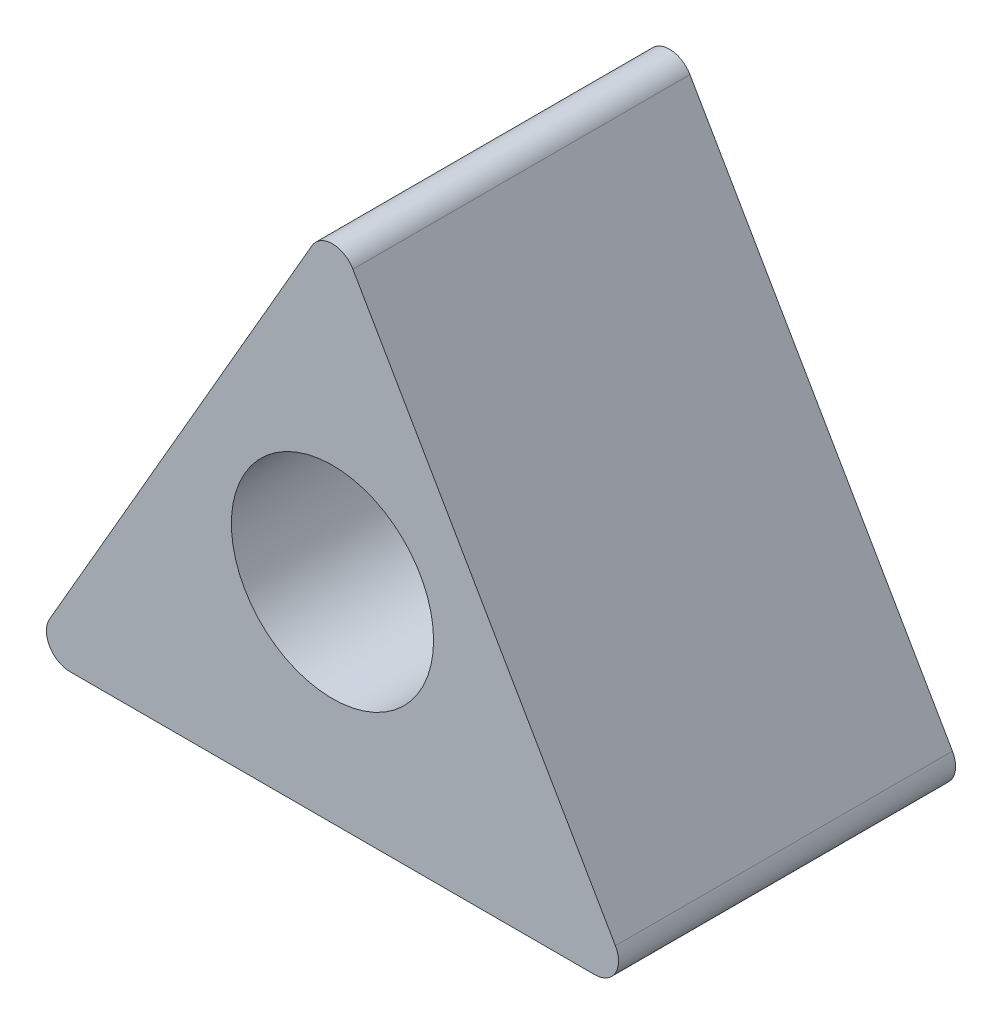
from build123d import *

# Parameters (mm, degrees)
SKETCH1_R           = 15
BOSS_EXTRUDE2_DEPTH = 50
FILLET1_R           = 3.5
FILLET2_R           = 3.5
FILLET3_R           = 3.5


with BuildPart() as part:
    # Sketch1 → Boss-Extrude2 (new body)
    with BuildSketch(Plane.XY):
        Polygon((0, 0), (89.999999993, 0.001126334), (44.999024562, 77.942849502), align=None)
        with Locations((45, 31)):
            Circle(SKETCH1_R, mode=Mode.SUBTRACT)
    extrude(amount=BOSS_EXTRUDE2_DEPTH)

    # Fillet1
    fillet1_edges = [part.edges().sort_by_distance(p)[0] for p in [
        (44.999024562, 77.942849502, 25),
    ]]
    fillet(fillet1_edges, radius=FILLET1_R)

    # Fillet2
    fillet2_edges = [part.edges().sort_by_distance(p)[0] for p in [
        (89.999999993, 0.001126334, 25),
    ]]
    fillet(fillet2_edges, radius=FILLET2_R)

    # Fillet3
    fillet3_edges = [part.edges().sort_by_distance(p)[0] for p in [
        (0, 0, 25),
    ]]
    fillet(fillet3_edges, radius=FILLET3_R)


solid = part.part
